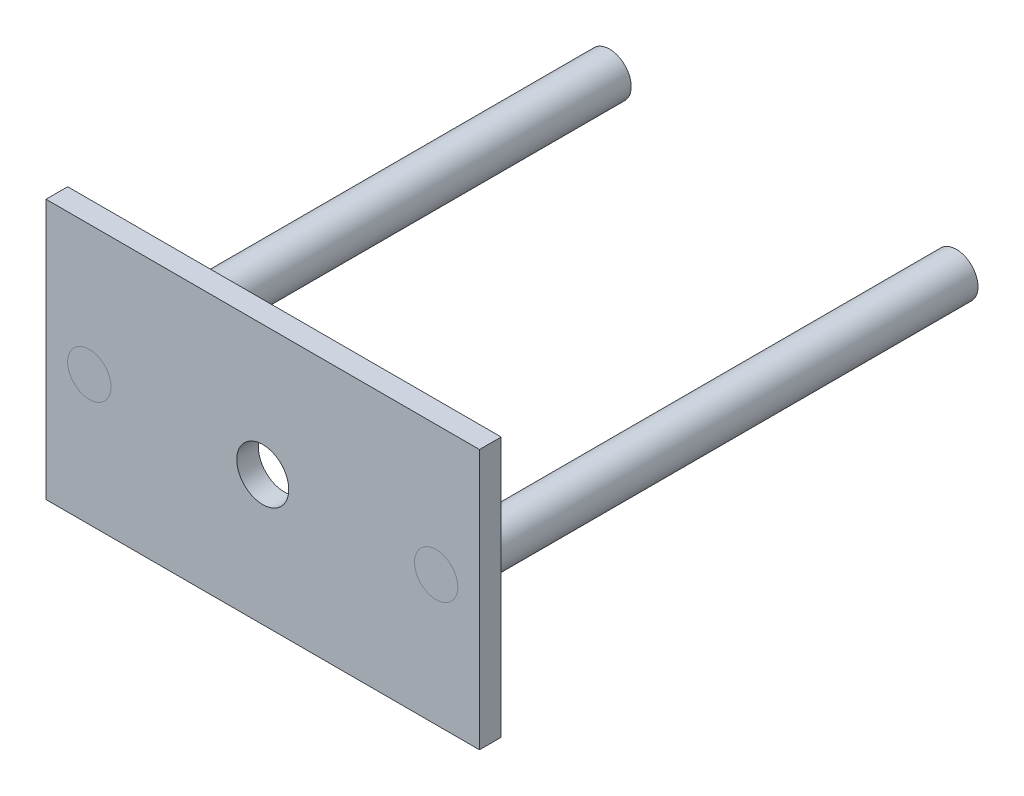
from build123d import *

# Parameters (mm, degrees)
SKETCH1_W             = 100
SKETCH1_H             = 60
SKETCH1_R             = 6
SKETCH1_R_2           = 5
BOSS_EXTRUDE1_DEPTH   = 5
SKETCH2_R             = 5
BOSS_EXTRUDE2_DEPTH   = 120
BOSS_EXTRUDE2_2_DEPTH = 120


with BuildPart() as part:
    # Sketch1 → Boss-Extrude1 (new body)
    with BuildSketch(Plane.XY):
        Rectangle(SKETCH1_W, SKETCH1_H)
        Circle(SKETCH1_R, mode=Mode.SUBTRACT)
        with Locations((-40, 0)):
            Circle(SKETCH1_R_2, mode=Mode.SUBTRACT)
        with Locations((40, 0)):
            Circle(SKETCH1_R_2, mode=Mode.SUBTRACT)
    extrude(amount=BOSS_EXTRUDE1_DEPTH)


with BuildPart() as body_2:
    # Sketch2 → Boss-Extrude2 (new body)
    with BuildSketch(Plane.XY.offset(5)):
        with Locations((40, 0)):
            Circle(SKETCH2_R)
    extrude(amount=-BOSS_EXTRUDE2_DEPTH)


with BuildPart() as body_3:
    # Sketch2 → Boss-Extrude2 2 (new body)
    with BuildSketch(Plane.XY.offset(5)):
        with Locations((-40, 0)):
            Circle(SKETCH2_R)
    extrude(amount=-BOSS_EXTRUDE2_2_DEPTH)


solid = Compound([part.part, body_2.part, body_3.part])
